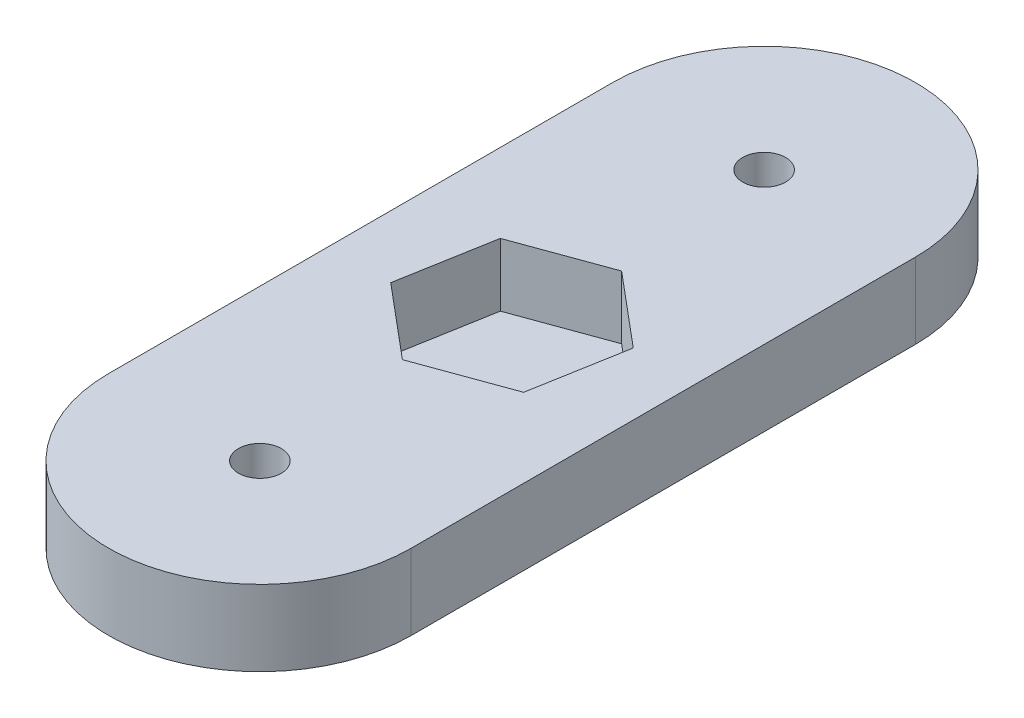
from build123d import *

# Parameters (mm, degrees)
SKETCH1_R           = 1.7
BOSS_EXTRUDE1_DEPTH = 6
CUT_EXTRUDE1_DEPTH  = 5


with BuildPart() as part:
    # Sketch1 → Boss-Extrude1 (new body)
    with BuildSketch(Plane(origin=(0, 0, 0), x_dir=(1, 0, 0), z_dir=(0, 1, 0))):
        with BuildLine():
            Line((-12, 0), (-12, 40))
            ThreePointArc((-12, 40), (0, 52), (12, 40))
            Line((12, 40), (12, 0))
            ThreePointArc((12, 0), (0, -12), (-12, 0))
        make_face()
        with Locations((0, 40)):
            Circle(SKETCH1_R, mode=Mode.SUBTRACT)
        Circle(SKETCH1_R, mode=Mode.SUBTRACT)
    extrude(amount=BOSS_EXTRUDE1_DEPTH)

    # Sketch2 → Cut-Extrude1 (cut)
    with BuildSketch(Plane(origin=(0, 6, 0), x_dir=(1, 0, 0), z_dir=(0, 1, 0))):
        Polygon((5.749587551, 15.175523207), (7.052913238, 22.567050484), (1.303325688, 27.391527277), (-5.749587551, 24.824476793), (-7.052913238, 17.432949516), (-1.303325688, 12.608472723), align=None)
    extrude(amount=-CUT_EXTRUDE1_DEPTH, mode=Mode.SUBTRACT)


solid = part.part
